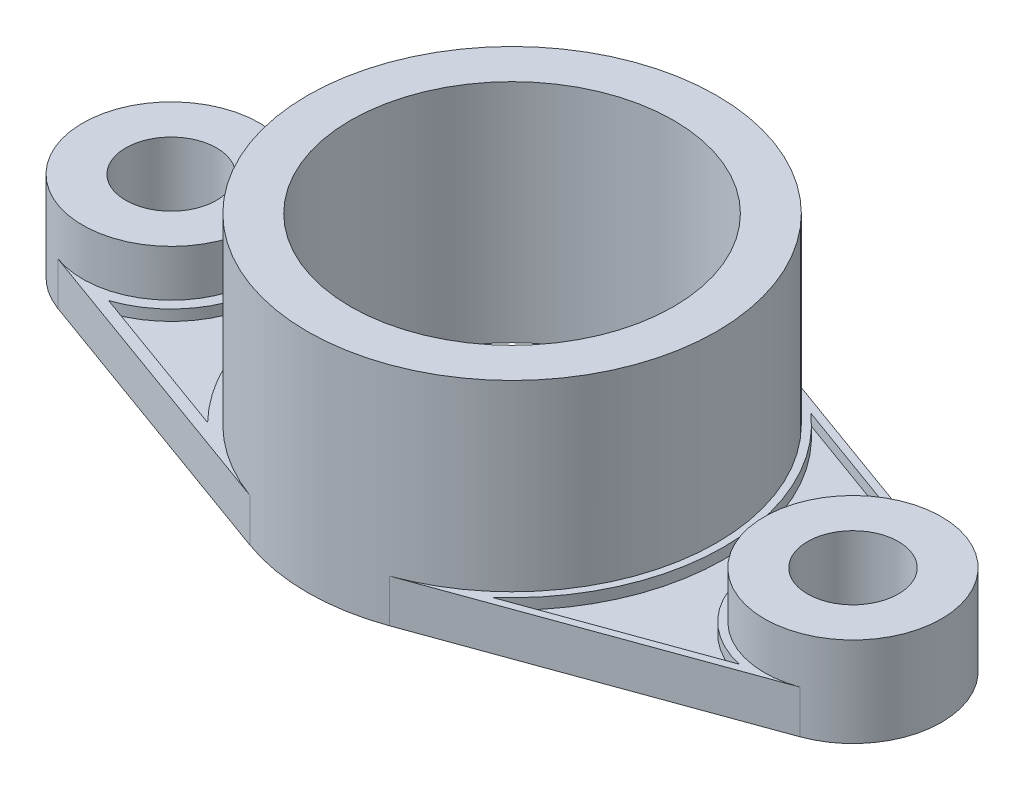
from build123d import *

# Parameters (mm, degrees)
SKETCH1_R           = 12.666666667
SKETCH1_R_2         = 45
BOSS_EXTRUDE1_DEPTH = 12
SKETCH2_R           = 57
SKETCH2_R_2         = 45
BOSS_EXTRUDE2_DEPTH = 51
SKETCH3_R           = 24.666666667
SKETCH3_R_2         = 12.666666667
BOSS_EXTRUDE3_DEPTH = 13
CUT_EXTRUDE1_DEPTH  = 3


with BuildPart() as part:
    # Sketch1 → Boss-Extrude1 (new body)
    with BuildSketch(Plane(origin=(0, 0, 0), x_dir=(1, 0, 0), z_dir=(0, 1, 0))):
        with BuildLine():
            Line((-19.4, 53.597014842), (-103.395321637, 23.194029815))
            ThreePointArc((-103.395321637, 23.194029815), (-119.666666667, 0), (-103.395321637, -23.194029815))
            Line((-103.395321637, -23.194029815), (-19.4, -53.597014842))
            ThreePointArc((-19.4, -53.597014842), (0, -57), (19.4, -53.597014842))
            Line((19.4, -53.597014842), (103.395321637, -23.194029815))
            ThreePointArc((103.395321637, -23.194029815), (119.666666667, 0), (103.395321637, 23.194029815))
            Line((103.395321637, 23.194029815), (19.4, 53.597014842))
            ThreePointArc((19.4, 53.597014842), (0, 57), (-19.4, 53.597014842))
        make_face()
        with Locations((-95, 0)):
            Circle(SKETCH1_R, mode=Mode.SUBTRACT)
        Circle(SKETCH1_R_2, mode=Mode.SUBTRACT)
        with Locations((95, 0)):
            Circle(SKETCH1_R, mode=Mode.SUBTRACT)
    extrude(amount=BOSS_EXTRUDE1_DEPTH)

    # Sketch2 → Boss-Extrude2 (add)
    with BuildSketch(Plane(origin=(0, 12, 0), x_dir=(1, 0, 0), z_dir=(0, 1, 0))):
        Circle(SKETCH2_R)
        Circle(SKETCH2_R_2, mode=Mode.SUBTRACT)
    extrude(amount=BOSS_EXTRUDE2_DEPTH)

    # Sketch3 → Boss-Extrude3 (add)
    with BuildSketch(Plane(origin=(0, 12, 0), x_dir=(1, 0, 0), z_dir=(0, 1, 0))):
        with Locations((95, 0)):
            Circle(SKETCH3_R)
        with Locations((95, 0)):
            Circle(SKETCH3_R_2, mode=Mode.SUBTRACT)
        with Locations((-95, 0)):
            Circle(SKETCH3_R)
        with Locations((-95, 0)):
            Circle(SKETCH3_R_2, mode=Mode.SUBTRACT)
    extrude(amount=BOSS_EXTRUDE3_DEPTH)

    # Sketch4 → Cut-Extrude1 (cut)
    with BuildSketch(Plane(origin=(0, 12, 0), x_dir=(1, 0, 0), z_dir=(0, 1, 0))):
        with BuildLine():
            Line((-42.970944355, 41.87478885), (-86.196761812, 26.228752198))
            ThreePointArc((-86.196761812, 26.228752198), (-67.333333333, 0), (-86.196761812, -26.228752198))
            Line((-86.196761812, -26.228752198), (-42.970944355, -41.87478885))
            ThreePointArc((-42.970944355, -41.87478885), (-60, 0), (-42.970944355, 41.87478885))
        make_face()
        with BuildLine():
            Line((38.798579703, -44.448511932), (89.505740572, -26.094524798))
            ThreePointArc((89.505740572, -26.094524798), (68.333333333, 0), (89.505740572, 26.094524798))
            Line((89.505740572, 26.094524798), (38.798579703, 44.448511932))
            ThreePointArc((38.798579703, 44.448511932), (59, 0), (38.798579703, -44.448511932))
        make_face()
    extrude(amount=-CUT_EXTRUDE1_DEPTH, mode=Mode.SUBTRACT)


solid = part.part
